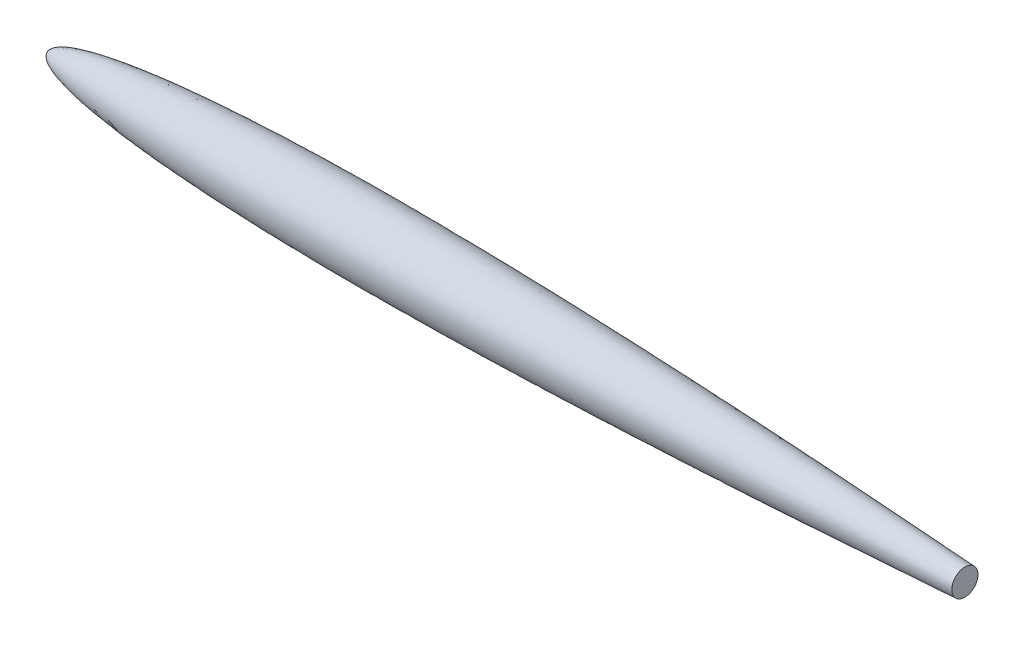
from build123d import *

# Parameters (mm, degrees)
CUTSKETCH_R        = 330
CUT_EXTRUDE1_DEPTH = 1981.000000056


with BuildPart() as part:
    # rootSketch → Revolve1 (revolve)
    with BuildSketch(Plane(origin=(0, 0, 0), x_dir=(1, 0, 0), z_dir=(0, 1, 0))):
        with BuildLine():
            Line((0, 0), (10999.999999956, 0))
            add(Edge.make_bspline(
                [(0, 0), (0.000193085, 1.416582005), (0.122535707, 4.240766735), (0.673873379, 8.454686711), (2.109656818, 13.93845879), (4.130019916, 19.114733958), (6.6108994, 23.964322659), (9.99141312, 29.368131534), (13.807367772, 34.371487293), (18.005055091, 39.082436475), (24.006567174, 45.012475537), (32.38394762, 52.235407337), (43.384048479, 60.194382801), (57.076069362, 68.618071155), (73.982979094, 77.724284629), (92.789267205, 86.643497962), (113.957785626, 95.516746756), (137.455558775, 104.311070441), (166.299503437, 114.136034239), (201.291019257, 124.83380424), (243.070199966, 136.204737597), (291.673004407, 147.963968929), (341.243287097, 158.777969553), (390.608018364, 168.603047356), (439.719156269, 177.608967602), (500.651651233, 187.980684512), (573.469223954, 199.282575084), (658.612232457, 211.186619601), (758.084154261, 223.607887379), (859.684753543, 234.995657417), (963.386980877, 245.464526813), (1069.170635517, 255.102838422), (1175.032596375, 263.835414151), (1280.957756037, 271.761542521), (1386.934581972, 278.961621427), (1492.954015963, 285.502236936), (1625.576964573, 292.926255548), (1784.827209806, 300.723903315), (1970.72108882, 308.376208714), (2183.266072594, 315.387382688), (2395.855799019, 320.860371187), (2608.476211675, 324.955727138), (2821.116716449, 327.806853247), (3033.769186051, 329.526860496), (3299.591922937, 330.384071895), (3618.580812409, 329.51376865), (3990.720403141, 326.052290468), (4415.985201528, 319.209100208), (4841.201558049, 309.857365651), (5266.363404579, 298.307410519), (5691.467689334, 284.815055747), (6116.513213618, 269.590680129), (6541.499783516, 252.805736724), (6966.427609798, 234.597307498), (7391.296846876, 215.071528971), (7816.107239786, 194.306117476), (8187.764015612, 175.096544249), (8506.288418891, 157.904884619), (8771.698784382, 143.095088026), (8984.01062255, 130.95609045), (9196.305479291, 118.523403252), (9382.048027901, 107.38440154), (9541.24447253, 97.647382898), (9673.900203702, 89.404934778), (9780.020008578, 82.733097615), (9912.663326878, 74.294734048), (10032.03499694, 66.58027009), (10138.136351112, 59.627723881), (10230.971046534, 53.471278218), (10284.016761583, 49.932402374), (10337.064143493, 46.372127364), (10390.104279802, 42.790919783), (10443.152990441, 39.18744375), (10496.183419271, 35.563459924), (10549.240167305, 31.915530826), (10602.249493916, 28.248814521), (10655.332945198, 24.554271665), (10708.28973189, 20.846283715), (10761.453592237, 17.100380429), (10814.258157127, 13.357501973), (10861.039415372, 10.020132172), (10900.208423325, 7.212345677), (10934.336848159, 4.754530233), (10958.871036751, 2.983522743), (10981.803250473, 1.321442896), (10993.97273069, 0.438031797), (10999.999999956, 0)],
                knots=[0, 0, 0, 0, 0, 0.000464454, 0.000928907, 0.001393361, 0.001857814, 0.002287128, 0.002716441, 0.003486019, 0.003922473, 0.004358926, 0.005488094, 0.007117503, 0.008377929, 0.009638355, 0.011796648, 0.013954941, 0.015918589, 0.017882237, 0.021809533, 0.025977713, 0.030145893, 0.034314073, 0.038482253, 0.042518279, 0.046554305, 0.054626357, 0.062698409, 0.070770462, 0.079497478, 0.088224494, 0.09695151, 0.105678526, 0.114405542, 0.123132558, 0.131859574, 0.14058659, 0.158058513, 0.175530436, 0.193002359, 0.210474282, 0.227946206, 0.24541813, 0.262890054, 0.280361977, 0.315305825, 0.350249672, 0.38519352, 0.420137368, 0.455081215, 0.490025063, 0.524968911, 0.559912758, 0.594856606, 0.629800453, 0.664744301, 0.699688149, 0.717160073, 0.734631996, 0.75210392, 0.769575844, 0.787047768, 0.79578373, 0.804519691, 0.813255653, 0.821991615, 0.839463539, 0.84383152, 0.848199501, 0.852567482, 0.856935463, 0.861303444, 0.865671425, 0.870039406, 0.874407387, 0.878775368, 0.883143349, 0.88751133, 0.891879311, 0.896247292, 0.900615273, 0.902799263, 0.904983254, 0.907167244, 0.909351235, 0.909351235, 0.909351235, 0.909351235, 0.909351235], degree=4))
        make_face()
    revolve(axis=Axis((0, 0, 0), (1, 0, 0)))

    # cutSketch → Cut-Extrude1 (cut, through all)
    with BuildSketch(Plane(origin=(9020, 0, 0), x_dir=(0, 0, -1), z_dir=(1, 0, 0))):
        Circle(CUTSKETCH_R)
    extrude(amount=CUT_EXTRUDE1_DEPTH, mode=Mode.SUBTRACT)


solid = part.part
